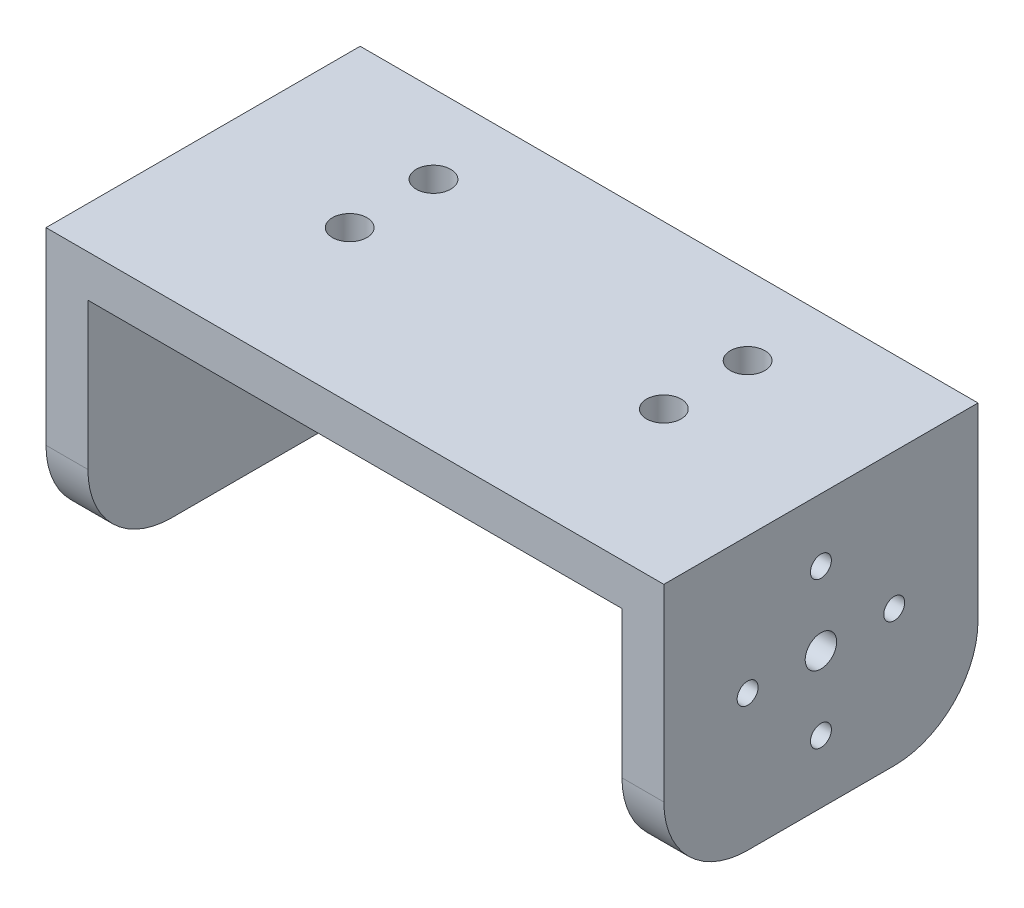
from build123d import *

# Parameters (mm, degrees)
EXTRUDE_1_DEPTH     = 30
FILLET_1_R          = 8
SKETCH_4_R          = 1.65
CUT_EXTRUDE_1_DEPTH = 10
SKETCH_5_R          = 1.65
CUT_EXTRUDE_2_DEPTH = 10
SKETCH_6_R          = 1
CUT_EXTRUDE_3_DEPTH = 10
SKETCH_7_R          = 1.5
CUT_EXTRUDE_4_DEPTH = 10


with BuildPart() as part:
    # 草图1 → 凸台-拉伸1 (new body)
    with BuildSketch(Plane.XY):
        Polygon((0, 0), (29.5, 0), (29.5, -26), (25.5, -26), (25.5, -4), (0, -4), (-25.5, -4), (-25.5, -26), (-29.5, -26), (-29.5, 0), align=None)
    extrude(amount=EXTRUDE_1_DEPTH)

    # 圆角1
    fillet_1_edges = [part.edges().sort_by_distance(p)[0] for p in [
        (27.5, -26, 0),
        (-27.5, -26, 0),
        (-27.5, -26, 30),
        (27.5, -26, 30),
    ]]
    fillet(fillet_1_edges, radius=FILLET_1_R)

    # 草图4 → 切除-拉伸1 (cut)
    with BuildSketch(Plane(origin=(0, 0, 0), x_dir=(1, 0, 0), z_dir=(0, 1, 0))):
        with Locations((15, -7.5)):
            Circle(SKETCH_4_R)
        with Locations((-15, -7.5)):
            Circle(SKETCH_4_R)
        with Locations((-15, -15.5)):
            Circle(SKETCH_4_R)
        with Locations((15, -15.5)):
            Circle(SKETCH_4_R)
    extrude(amount=-CUT_EXTRUDE_1_DEPTH, mode=Mode.SUBTRACT)

    # 草图5 → 切除-拉伸2 (cut)
    with BuildSketch(Plane.ZY.offset(29.5)):
        with Locations((15, -13)):
            Circle(SKETCH_5_R)
    extrude(amount=-CUT_EXTRUDE_2_DEPTH, mode=Mode.SUBTRACT)

    # 草图6 → 切除-拉伸3 (cut)
    with BuildSketch(Plane(origin=(29.5, 0, 0), x_dir=(0, 0, -1), z_dir=(1, 0, 0))):
        with Locations((-15, -6)):
            Circle(SKETCH_6_R)
        with Locations((-8, -13)):
            Circle(SKETCH_6_R)
        with Locations((-15, -20)):
            Circle(SKETCH_6_R)
        with Locations((-22, -13)):
            Circle(SKETCH_6_R)
    extrude(amount=-CUT_EXTRUDE_3_DEPTH, mode=Mode.SUBTRACT)

    # 草图7 → 切除-拉伸4 (cut)
    with BuildSketch(Plane(origin=(29.5, 0, 0), x_dir=(0, 0, -1), z_dir=(1, 0, 0))):
        with Locations((-15, -13)):
            Circle(SKETCH_7_R)
    extrude(amount=-CUT_EXTRUDE_4_DEPTH, mode=Mode.SUBTRACT)


solid = part.part
